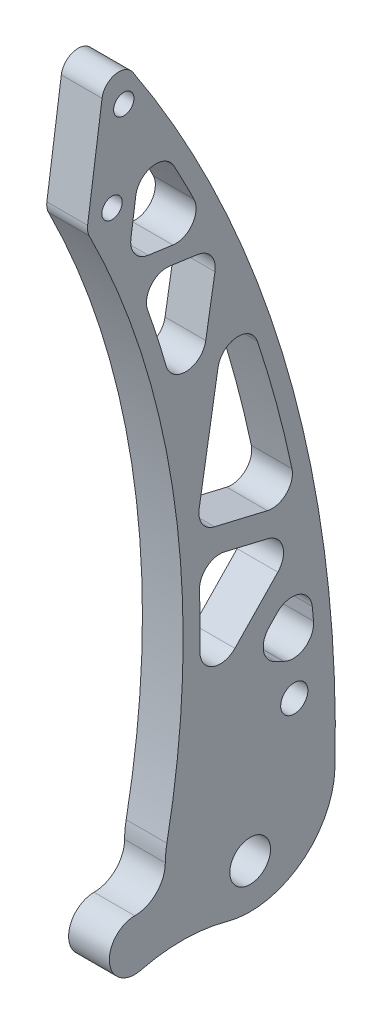
from build123d import *

# Parameters (mm, degrees)
SKETCH1_R           = 6
BOSS_EXTRUDE1_DEPTH = 12
SKETCH3_R           = 3
CUT_EXTRUDE2_DEPTH  = 13
CUT_EXTRUDE3_DEPTH  = 13
FILLET1_R           = 6
SKETCH2_R           = 4
CUT_EXTRUDE1_DEPTH  = 13.0000001
SKETCH5_R           = 7.5
BOSS_EXTRUDE2_DEPTH = 12
FILLET2_R           = 5


with BuildPart() as part:
    # Sketch1 → Boss-Extrude1 (new body)
    with BuildSketch(Plane(origin=(0, 0, 0), x_dir=(0, 0, -1), z_dir=(1, 0, 0))):
        with BuildLine():
            ThreePointArc((24.992781164, -0.60074095), (9.243822678, 113.703988064), (-41.858816097, 217.155044504))
            Line((-41.858816097, 217.155044504), (-48.12160564, 172.59298141))
            ThreePointArc((-48.12160564, 172.59298141), (-22.274376436, 90.661190514), (-24.538993202, 4.778892408))
            ThreePointArc((-24.538993202, 4.778892408), (2.400538477, 24.88448141), (25, 0))
            ThreePointArc((25, 0), (24.998195226, -0.30039216), (24.992781164, -0.60074095))
        make_face()
        with BuildLine():
            ThreePointArc((-24.538993202, 4.778892408), (-2.699369305, -24.853840857), (24.992781164, -0.60074095))
            ThreePointArc((24.992781164, -0.60074095), (24.998195226, -0.30039216), (25, 0))
            ThreePointArc((25, 0), (2.400538477, 24.88448141), (-24.538993202, 4.778892408))
        make_face()
        with Locations((0, -12)):
            Circle(SKETCH1_R, mode=Mode.SUBTRACT)
    extrude(amount=BOSS_EXTRUDE1_DEPTH)

    # Sketch3 → Cut-Extrude2 (cut, through all)
    with BuildSketch(Plane(origin=(12, 0, 0), x_dir=(0, 0, -1), z_dir=(1, 0, 0))):
        with Locations((-40.714528231, 175)):
            Circle(SKETCH3_R)
        with Locations((-37.235200707, 199.756701719)):
            Circle(SKETCH3_R)
    extrude(amount=-CUT_EXTRUDE2_DEPTH, mode=Mode.SUBTRACT)

    # Sketch4 → Cut-Extrude3 (cut, through all)
    with BuildSketch(Plane(origin=(12, 0, 0), x_dir=(0, 0, -1), z_dir=(1, 0, 0))):
        with BuildLine():
            ThreePointArc((-11.749836025, 155.008629259), (-20.960958666, 173.77628952), (-31.260870979, 191.969190837))
            Line((-31.260870979, 191.969190837), (-35.976814508, 158.413509038))
            Line((-35.976814508, 158.413509038), (-11.749836025, 155.008629259))
        make_face()
        with BuildLine():
            Line((-9.354323007, 149.622823998), (-33.760235475, 153.052851308))
            ThreePointArc((-33.760235475, 153.052851308), (-24.416431689, 125.419954523), (-18.166319592, 96.927503721))
            Line((-18.166319592, 96.927503721), (-9.354323007, 149.622823998))
        make_face()
        with BuildLine():
            ThreePointArc((14.161868129, 72.691486719), (5.930300275, 107.334766496), (-5.730334656, 140.979158838))
            Line((-5.730334656, 140.979158838), (-15.958464631, 79.815428272))
            Line((-15.958464631, 79.815428272), (14.161868129, 72.691486719))
        make_face()
        with BuildLine():
            Line((15.468075791, 65.189422352), (-15.356589243, 72.479949778))
            ThreePointArc((-15.356589243, 72.479949778), (-14.750380465, 52.717361117), (-15.619336812, 32.964581198))
            Line((-15.619336812, 32.964581198), (15.468075791, 65.189422352))
        make_face()
        with BuildLine():
            ThreePointArc((19.721068997, 24.377203305), (18.614609922, 40.455333735), (16.779570125, 56.466678425))
            Line((16.779570125, 56.466678425), (-2, 37))
            ThreePointArc((-2, 37), (10.561248293, 33.615157675), (19.721068997, 24.377203305))
        make_face()
    extrude(amount=-CUT_EXTRUDE3_DEPTH, mode=Mode.SUBTRACT)

    # Fillet1
    fillet1_edges = [part.edges().sort_by_distance(p)[0] for p in [
        (6, 155.008629259, 11.749836025),
        (6, 158.413509038, 35.976814508),
        (6, 191.969190837, 31.260870979),
        (6, 96.927503721, 18.166319592),
        (6, 153.052851308, 33.760235475),
        (6, 149.622823998, 9.354323007),
        (6, 72.691486719, -14.161868129),
        (6, 79.815428272, 15.958464631),
        (6, 140.979158838, 5.730334656),
        (6, 32.964581198, 15.619336812),
        (6, 72.479949778, 15.356589243),
        (6, 65.189422352, -15.468075791),
        (6, 24.377203305, -19.721068997),
        (6, 37, 2),
        (6, 56.466678425, -16.779570125),
    ]]
    fillet(fillet1_edges, radius=FILLET1_R)

    # Sketch2 → Cut-Extrude1 (cut, through all)
    with BuildSketch(Plane(origin=(12, 0, 0), x_dir=(0, 0, -1), z_dir=(1, 0, 0))):
        with Locations((13, 23)):
            Circle(SKETCH2_R)
    extrude(amount=-CUT_EXTRUDE1_DEPTH, mode=Mode.SUBTRACT)

    # Sketch5 → Boss-Extrude2 (add)
    with BuildSketch(Plane(origin=(12, 0, 0), x_dir=(0, 0, -1), z_dir=(1, 0, 0))):
        with BuildLine():
            ThreePointArc((-34, -9), (-28.696699141, -11.196699141), (-26.5, -16.5))
            ThreePointArc((-26.5, -16.5), (-28.087357429, -21.114180081), (-32.177508753, -23.775199355))
            ThreePointArc((-32.177508753, -23.775199355), (-19.40613231, -22.280390349), (-6.675855702, -24.092176129))
            ThreePointArc((-6.675855702, -24.092176129), (-19.898447082, -15.134457497), (-25, 0))
            ThreePointArc((-25, 0), (-27.636038969, -6.363961031), (-34, -9))
        make_face()
        with Locations((-34, -16.5)):
            Circle(SKETCH5_R)
    extrude(amount=-BOSS_EXTRUDE2_DEPTH)

    # Fillet2
    fillet2_edges = [part.edges().sort_by_distance(p)[0] for p in [
        (6, 172.59298141, 48.12160564),
        (6, 217.155044504, 41.858816097),
    ]]
    fillet(fillet2_edges, radius=FILLET2_R)


solid = part.part
